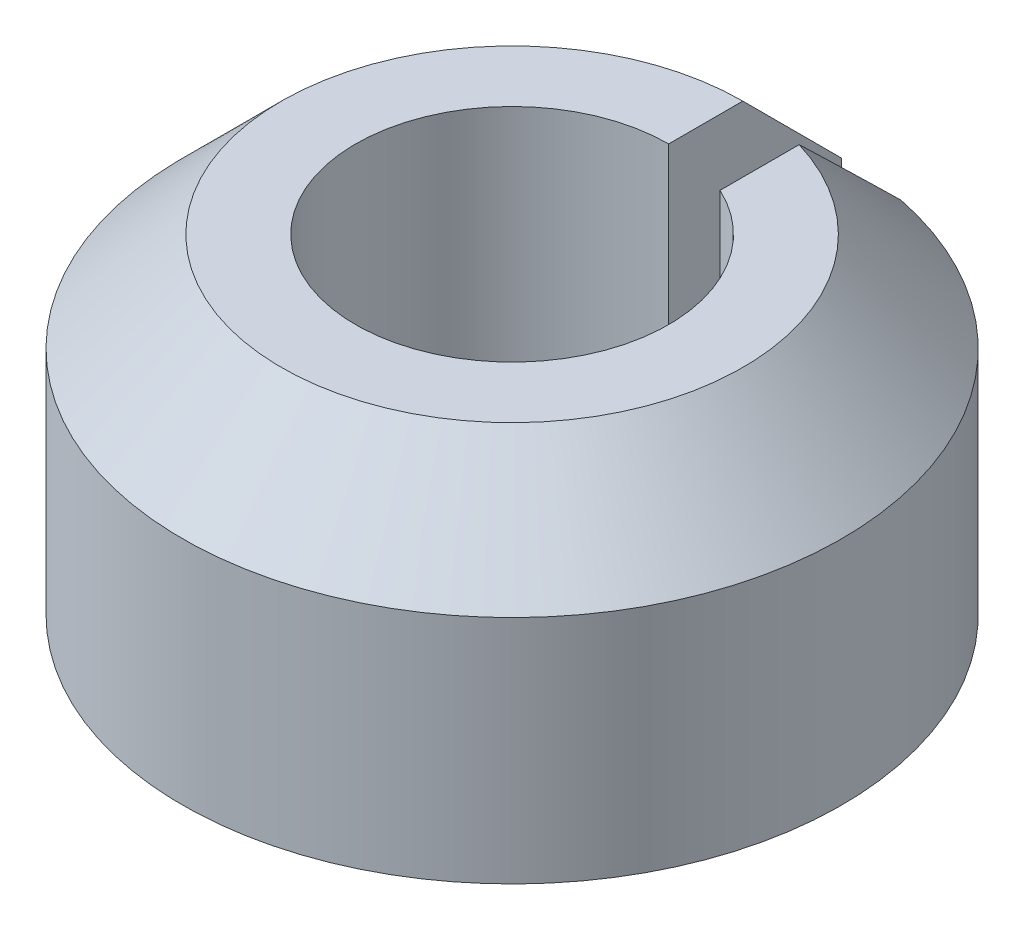
from build123d import *

# Parameters (mm, degrees)
EXTRUDE_1_DEPTH = 2
CHAMFER_1_SIZE  = 0.6


with BuildPart() as part:
    # Эскиз1 → Бобышка-Вытянуть1 (new body)
    with BuildSketch(Plane(origin=(0, 0, 0), x_dir=(1, 0, 0), z_dir=(0, 1, 0))):
        with BuildLine():
            Line((0, 0.95), (0, 2))
            ThreePointArc((0, 2), (-0.201017924, -1.989872306), (0.4, 1.959591794))
            Line((0.4, 1.959591794), (0.4, 0.861684397))
            ThreePointArc((0.4, 0.861684397), (-0.204816775, -0.92765839), (0, 0.95))
        make_face()
    extrude(amount=EXTRUDE_1_DEPTH)

    # Фаска1
    chamfer_1_edges = [part.edges().sort_by_distance(p)[0] for p in [
        (-0.201017924, 2, 1.989872306),
    ]]
    chamfer(chamfer_1_edges, length=CHAMFER_1_SIZE)


solid = part.part
